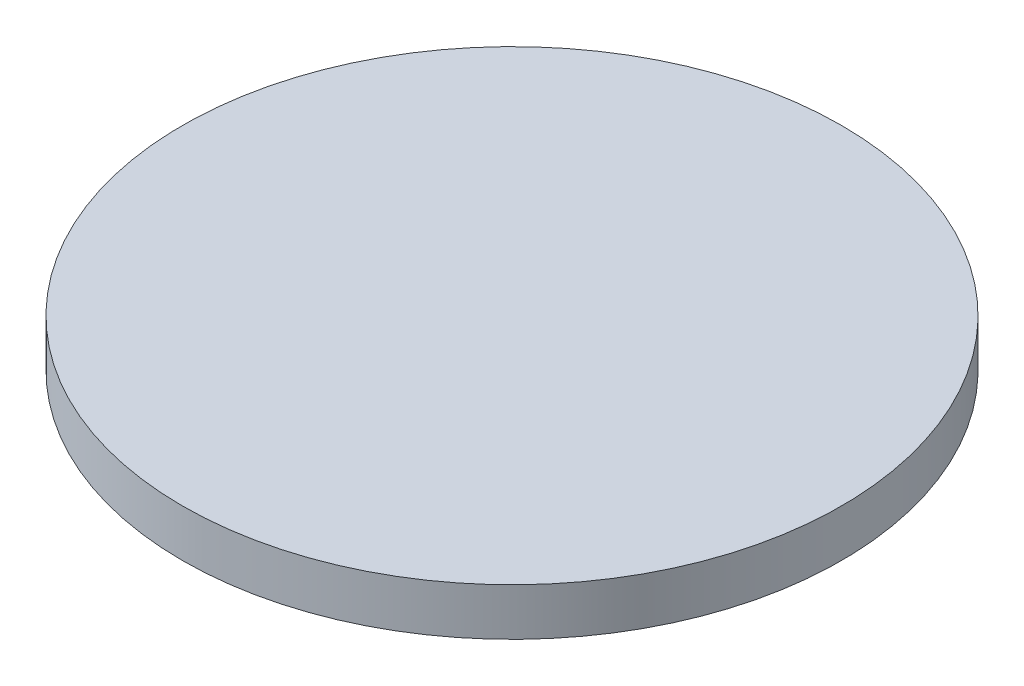
from build123d import *

# Parameters (mm, degrees)
SKETCH1_R           = 10.45
BOSS_EXTRUDE1_DEPTH = 1.5


with BuildPart() as part:
    # Sketch1 → Boss-Extrude1 (new body)
    with BuildSketch(Plane(origin=(0, 0, 0), x_dir=(1, 0, 0), z_dir=(0, 1, 0))):
        Circle(SKETCH1_R)
    extrude(amount=BOSS_EXTRUDE1_DEPTH)


solid = part.part
